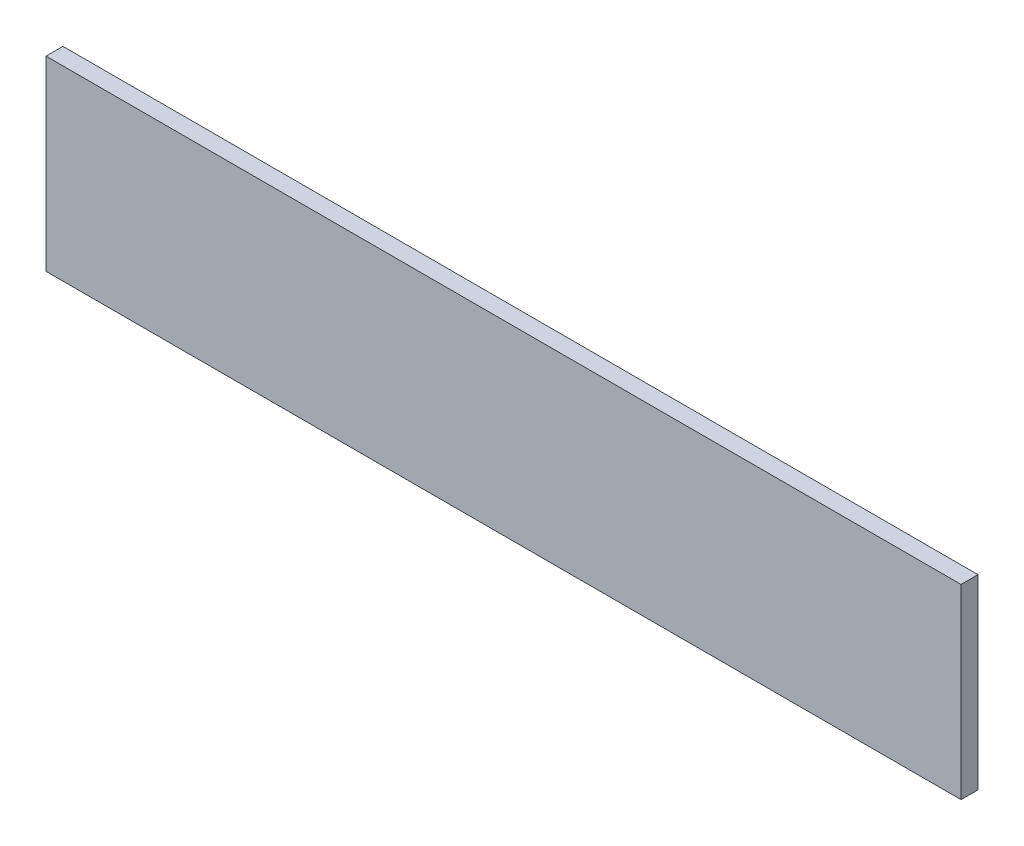
from build123d import *

# Parameters (mm, degrees)
SKETCH1_W           = 685.8
SKETCH1_H           = 139.7
BOSS_EXTRUDE1_DEPTH = 12.7


with BuildPart() as part:
    # Sketch1 → Boss-Extrude1 (new body)
    with BuildSketch(Plane.XY):
        Rectangle(SKETCH1_W, SKETCH1_H)
    extrude(amount=BOSS_EXTRUDE1_DEPTH)


solid = part.part
